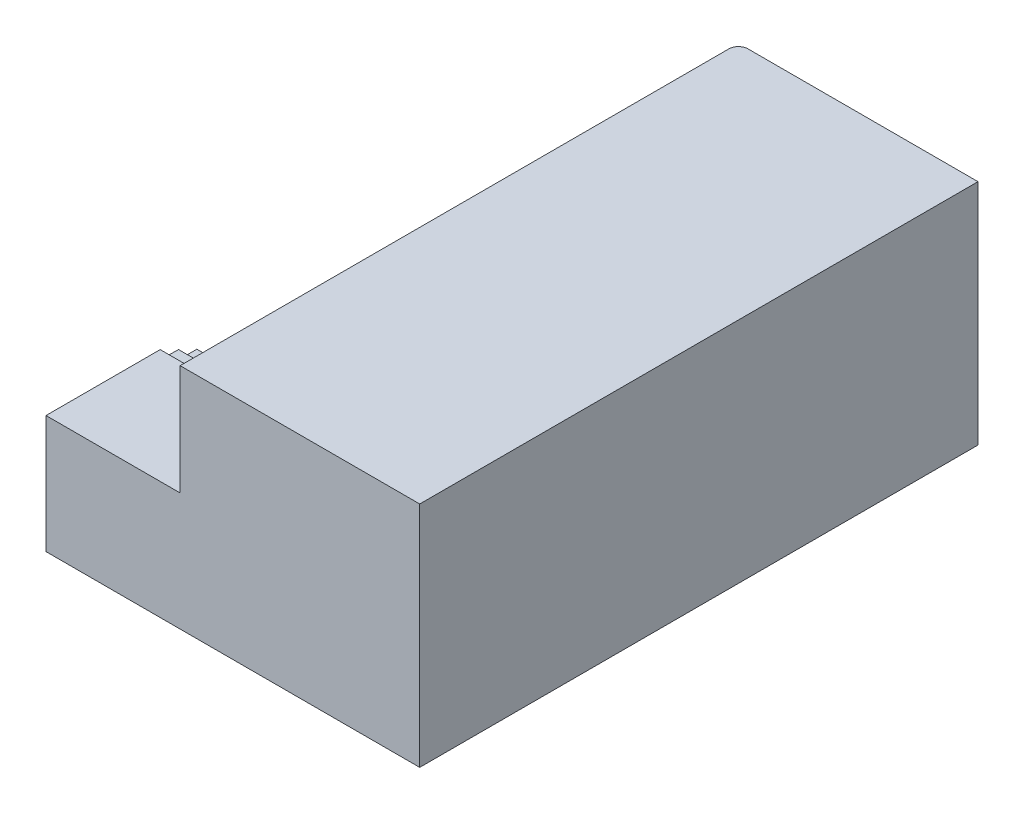
from build123d import *

# Parameters (mm, degrees)
BOSS_EXTRUDE1_DEPTH = 280
SKETCH2_W           = 280
SKETCH2_H           = 5
BOSS_EXTRUDE2_DEPTH = 497.896133892
SKETCH3_W           = 280
SKETCH3_H           = 246.044177264
BOSS_EXTRUDE3_DEPTH = 200
SKETCH4_W           = 280
SKETCH4_H           = 4.725360331
BOSS_EXTRUDE4_DEPTH = 467.31
SKETCH5_W           = 1165.206133892
SKETCH5_H           = 476.142057012
BOSS_EXTRUDE5_DEPTH = 500
FILLET1_R           = 20


with BuildPart() as part:
    # Sketch1 → Boss-Extrude1 (new body)
    with BuildSketch(Plane(origin=(0, 0, 0), x_dir=(0, 0, -1), z_dir=(1, 0, 0))):
        Polygon((-98.3, 73.71314577), (-60, 73.71314577), (-60, 55.21314577), (-21.703866108, 54.668968506), (-21.703866108, 36.168968506), (16.596133892, 36.168968506), (16.596133892, 17.668968506), (54.896133892, 17.668968506), (54.896133892, -0.831031494), (93.196133892, -0.831031494), (93.196133892, -19.331031494), (131.496133892, -19.331031494), (131.496133892, -37.831031494), (169.796133892, -37.831031494), (169.796133892, -56.331031494), (208.096133892, -56.331031494), (208.096133892, -74.831031494), (246.396133892, -74.831031494), (246.396133892, -93.331031494), (284.696133892, -93.331031494), (284.696133892, -111.831031494), (322.996133892, -111.831031494), (322.996133892, -130.331031494), (361.296133892, -130.331031494), (361.296133892, -148.831031494), (399.596133892, -148.831031494), (399.596133892, -167.331031494), (-98.3, -167.331031494), align=None)
    extrude(amount=-BOSS_EXTRUDE1_DEPTH)

    # Sketch2 → Boss-Extrude2 (add)
    with BuildSketch(Plane.XY.offset(98.3)):
        with Locations((-140, -169.831031494)):
            Rectangle(SKETCH2_W, SKETCH2_H)
    extrude(amount=-BOSS_EXTRUDE2_DEPTH)

    # Sketch3 → Boss-Extrude3 (add)
    with BuildSketch(Plane.XY.offset(98.3)):
        with Locations((-140, -49.308942862)):
            Rectangle(SKETCH3_W, SKETCH3_H)
    extrude(amount=BOSS_EXTRUDE3_DEPTH)

    # Sketch4 → Boss-Extrude4 (add)
    with BuildSketch(Plane(origin=(0, 0, -399.596133892), x_dir=(-1, 0, 0), z_dir=(0, 0, -1))):
        with Locations((140, -169.968351329)):
            Rectangle(SKETCH4_W, SKETCH4_H)
    extrude(amount=BOSS_EXTRUDE4_DEPTH)

    # Sketch5 → Boss-Extrude5 (add)
    with BuildSketch(Plane(origin=(0, 0, 0), x_dir=(0, 0, -1), z_dir=(1, 0, 0))):
        with Locations((284.303066946, 65.739997012)):
            Rectangle(SKETCH5_W, SKETCH5_H)
    extrude(amount=BOSS_EXTRUDE5_DEPTH)

    # Fillet1
    fillet1_edges = [part.edges().sort_by_distance(p)[0] for p in [
        (0, 68.102677177, -866.906133892),
    ]]
    fillet(fillet1_edges, radius=FILLET1_R)


solid = part.part
